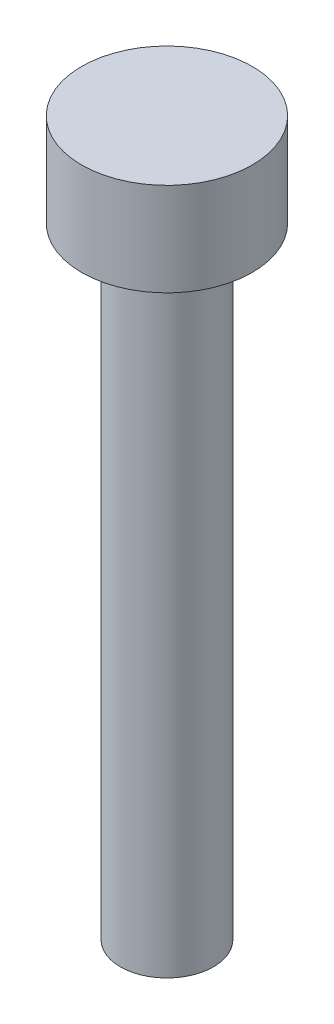
from build123d import *

# Parameters (mm, degrees)
SKETCH1_R           = 1.5
BOSS_EXTRUDE1_DEPTH = 20
SKETCH2_R           = 2.75
BOSS_EXTRUDE2_DEPTH = 3


with BuildPart() as part:
    # Sketch1 → Boss-Extrude1 (new body)
    with BuildSketch(Plane(origin=(0, 0, 0), x_dir=(1, 0, 0), z_dir=(0, 1, 0))):
        Circle(SKETCH1_R)
    extrude(amount=BOSS_EXTRUDE1_DEPTH)

    # Sketch2 → Boss-Extrude2 (add)
    with BuildSketch(Plane(origin=(0, 20, 0), x_dir=(1, 0, 0), z_dir=(0, 1, 0))):
        Circle(SKETCH2_R)
    extrude(amount=BOSS_EXTRUDE2_DEPTH)


solid = part.part
